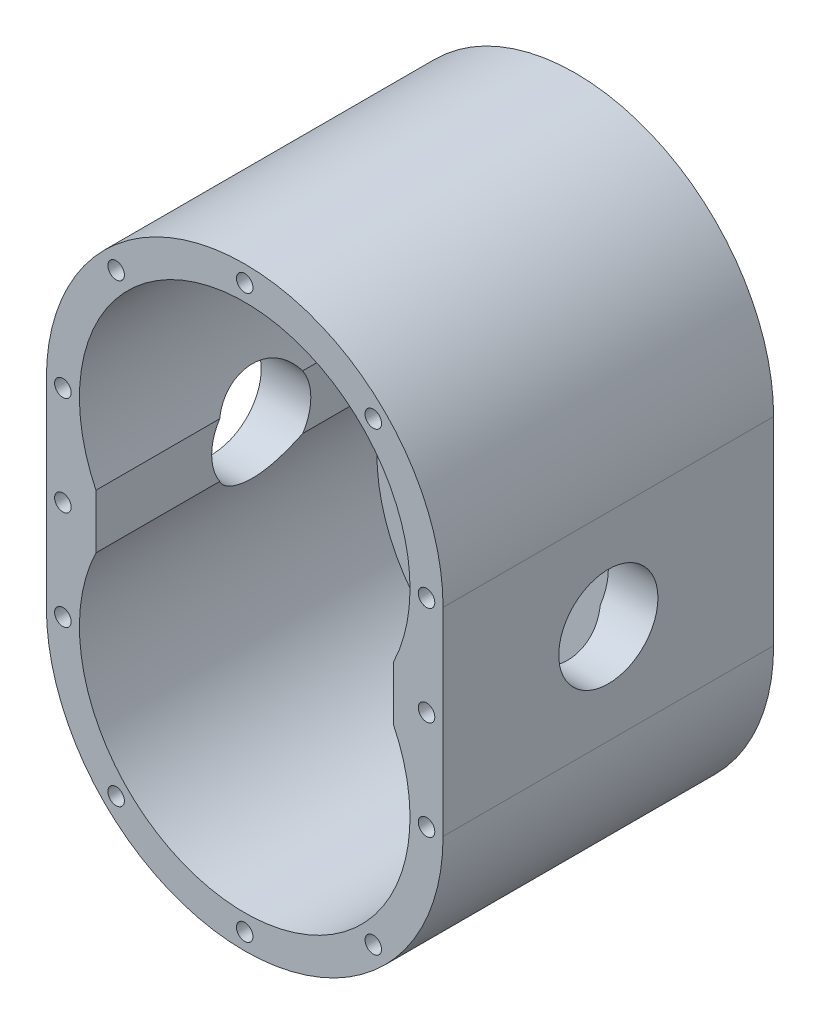
from build123d import *

# Parameters (mm, degrees)
OUTER_HOUSING_EXTRUDE_DEPTH            = 50
INNER_HOUSING_CUT_DEPTH                = 90
SKETCH3_R                              = 10
SHAFT_BEARING_INSERT_HOLE_DEPTH        = 7
HIGH_PRESSURE_OUTLET_HOLE_REACH        = 122
SKETCH4_R                              = 15
LOW_PRESSURE_INLET_HOLE_REACH          = 122
SKETCH5_R                              = 15
HOUSING_COVER_TOP_FASTENER_HOLES_COUNT = 8
M6X1_0_TAPPED_HOLE2_D                  = 5
M6X1_0_TAPPED_HOLE2_DEPTH              = 17
M6X1_0_TAPPED_HOLE2_TIP                = 1.502151548


with BuildPart() as part:
    # Sketch1 → Outer Housing Extrude (new body, symmetric)
    with BuildSketch(Plane.XY):
        with BuildLine():
            Line((-60, 30), (-60, -30))
            ThreePointArc((-60, -30), (0, -90), (60, -30))
            Line((60, -30), (60, 30))
            ThreePointArc((60, 30), (0, 90), (-60, 30))
        make_face()
    extrude(amount=OUTER_HOUSING_EXTRUDE_DEPTH, both=True)

    # Sketch2 → Inner Housing Cut (cut)
    with BuildSketch(Plane.XY.offset(50)):
        with BuildLine():
            Line((-45, 8.205505282), (-45, -8.205505282))
            ThreePointArc((-45, -8.205505282), (0, -80), (45, -8.205505282))
            Line((45, -8.205505282), (45, 8.205505282))
            ThreePointArc((45, 8.205505282), (0, 80), (-45, 8.205505282))
        make_face()
    extrude(amount=-INNER_HOUSING_CUT_DEPTH, mode=Mode.SUBTRACT)

    # Sketch3 → Shaft Bearing Insert Hole (cut)
    with BuildSketch(Plane.XY.offset(-40)):
        with Locations((0, 30)):
            Circle(SKETCH3_R)
        with Locations((0, -30)):
            Circle(SKETCH3_R)
    extrude(amount=-SHAFT_BEARING_INSERT_HOLE_DEPTH, mode=Mode.SUBTRACT)

    # Sketch4 → High Pressure Outlet Hole (cut, up to next)
    with BuildSketch(Plane.ZY.offset(60), mode=Mode.PRIVATE) as high_pressure_outlet_hole_sk1:
        Circle(SKETCH4_R)
    high_pressure_outlet_hole_tool1 = extrude(high_pressure_outlet_hole_sk1.sketch, amount=-HIGH_PRESSURE_OUTLET_HOLE_REACH, mode=Mode.PRIVATE) & part.part
    add(high_pressure_outlet_hole_tool1.solids().sort_by_distance((-60, 0, 0))[0], mode=Mode.SUBTRACT)

    # Sketch5 → Low Pressure Inlet Hole (cut, up to next)
    with BuildSketch(Plane(origin=(60, 0, 0), x_dir=(0, 0, -1), z_dir=(1, 0, 0)), mode=Mode.PRIVATE) as low_pressure_inlet_hole_sk1:
        Circle(SKETCH5_R)
    low_pressure_inlet_hole_tool1 = extrude(low_pressure_inlet_hole_sk1.sketch, amount=-LOW_PRESSURE_INLET_HOLE_REACH, mode=Mode.PRIVATE) & part.part
    add(low_pressure_inlet_hole_tool1.solids().sort_by_distance((60, 0, 0))[0], mode=Mode.SUBTRACT)

    # Sketch7 → M6x1.0 Tapped Hole1 (revolve, cut)
    with BuildSketch(Plane(origin=(0, 85, 50), x_dir=(0, -1, 0), z_dir=(1, 0, 0))):
        Polygon((0, 0), (0, 18.502151548), (2.5, 17), (2.5, 0), align=None)
    m6x1_0_tapped_hole1 = revolve(axis=Axis((0, 85, 56.35), (0, 0, -1)), mode=Mode.SUBTRACT)

    # Housing Cover Top Fastener Holes: M6x1.0 Tapped Hole1 ×8 about axis, 3 skipped
    housing_cover_top_fastener_holes_axis = Axis((0, 30, 0), (0, 0, 1))
    add([m6x1_0_tapped_hole1.rotate(housing_cover_top_fastener_holes_axis, i * 360 / HOUSING_COVER_TOP_FASTENER_HOLES_COUNT) for i in range(1, HOUSING_COVER_TOP_FASTENER_HOLES_COUNT) if i not in (3, 4, 5)], mode=Mode.SUBTRACT)

    # Housing Cover Bottom Fastener Holes: M6x1.0 Tapped Hole1 across plane
    add(m6x1_0_tapped_hole1.mirror(Plane.ZX), mode=Mode.SUBTRACT)

    # Housing Cover Bottom Fastener Holes copy → Housing Cover Bottom Fastener Holes  2 (revolve, cut)
    with BuildSketch(Plane(origin=(-38.890872965, -68.890872965, 50), x_dir=(0.707106781, 0.707106781, 0), z_dir=(0.707106781, -0.707106781, 0))):
        Polygon((0, 0), (0, -18.502151548), (2.5, -17), (2.5, 0), align=None)
    revolve(axis=Axis((-38.890872965, -68.890872965, 56.35), (0, 0, 1)), mode=Mode.SUBTRACT)

    # Housing Cover Bottom Fastener Holes  3 → Housing Cover Bottom Fastener Holes  4 (revolve, cut)
    with BuildSketch(Plane(origin=(-55, -30, 50), x_dir=(1, 0, 0), z_dir=(0, -1, 0))):
        Polygon((0, 0), (0, -18.502151548), (2.5, -17), (2.5, 0), align=None)
    revolve(axis=Axis((-55, -30, 56.35), (0, 0, 1)), mode=Mode.SUBTRACT)

    # Housing Cover Bottom Fastener Holes  5 → Housing Cover Bottom Fastener Holes  6 (revolve, cut)
    with BuildSketch(Plane(origin=(55, -30, 50), x_dir=(-1, 0, 0), z_dir=(0, 1, 0))):
        Polygon((0, 0), (0, -18.502151548), (2.5, -17), (2.5, 0), align=None)
    revolve(axis=Axis((55, -30, 56.35), (0, 0, 1)), mode=Mode.SUBTRACT)

    # Housing Cover Bottom Fastener Holes  7 → Housing Cover Bottom Fastener Holes  8 (revolve, cut)
    with BuildSketch(Plane(origin=(38.890872965, -68.890872965, 50), x_dir=(-0.707106781, 0.707106781, 0), z_dir=(0.707106781, 0.707106781, 0))):
        Polygon((0, 0), (0, -18.502151548), (2.5, -17), (2.5, 0), align=None)
    revolve(axis=Axis((38.890872965, -68.890872965, 56.35), (0, 0, 1)), mode=Mode.SUBTRACT)

    # M6x1.0 Tapped Hole2
    with Locations(Plane.XY.offset(50)):
        with Locations((-55, 0), (55, 0)):
            Hole(M6X1_0_TAPPED_HOLE2_D / 2, depth=M6X1_0_TAPPED_HOLE2_DEPTH)
            with Locations((0, 0, -(M6X1_0_TAPPED_HOLE2_DEPTH + M6X1_0_TAPPED_HOLE2_TIP / 2))):  # 118° drill point
                Cone(0, M6X1_0_TAPPED_HOLE2_D / 2, M6X1_0_TAPPED_HOLE2_TIP, mode=Mode.SUBTRACT)


solid = part.part
